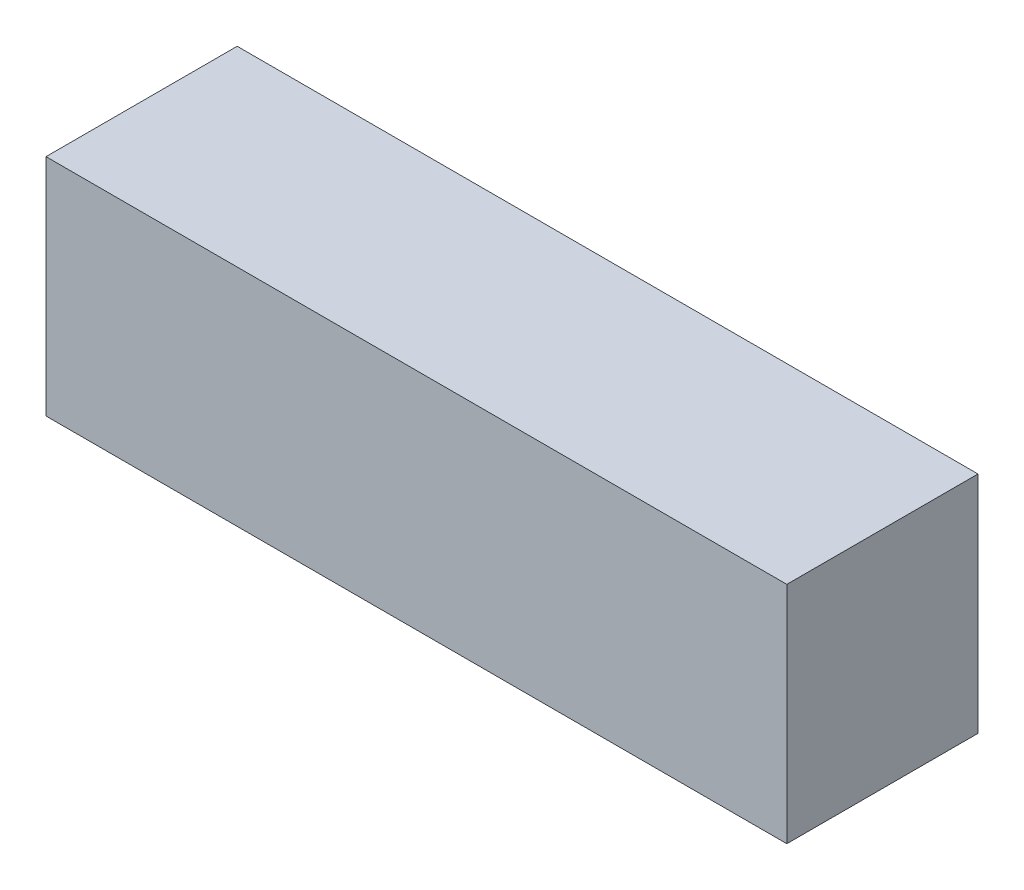
from build123d import *

# Parameters (mm, degrees)
ESBO_O1_W                = 155
ESBO_O1_H                = 47
RESSALTO_EXTRUS_O1_DEPTH = 40


with BuildPart() as part:
    # Esboço1 → Ressalto-extrusão1 (new body)
    with BuildSketch(Plane.XY):
        with Locations((-9.804683131, 5.062068966)):
            Rectangle(ESBO_O1_W, ESBO_O1_H)
    extrude(amount=RESSALTO_EXTRUS_O1_DEPTH)


solid = part.part
